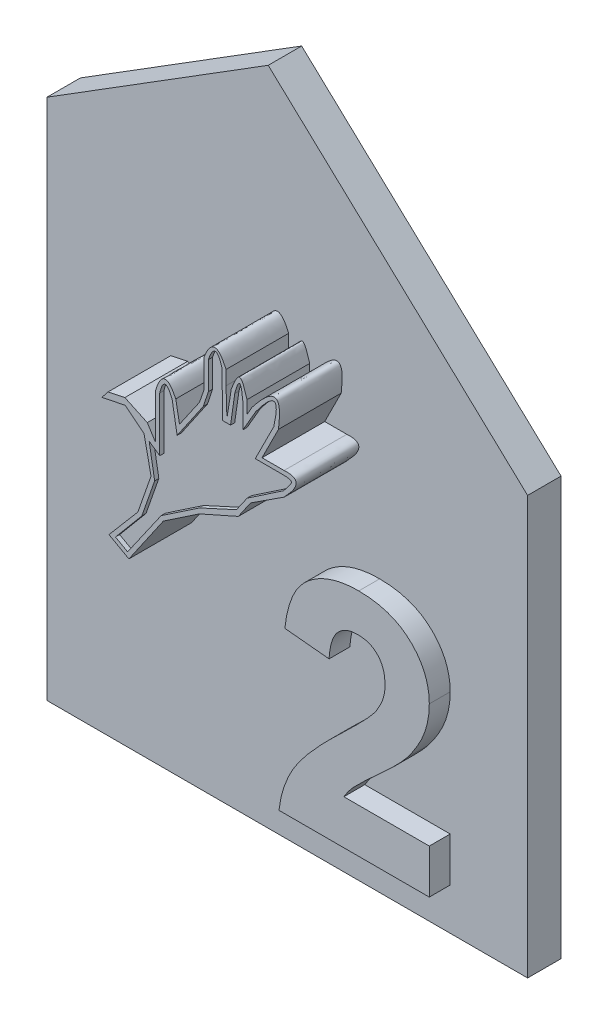
from build123d import *

# Parameters (mm, degrees)
P_IDAT_VYSUNUT_M5_DEPTH = 1.6
P_IDAT_VYSUNUT_M6_DEPTH = 1
P_IDAT_VYSUNUT_M7_DEPTH = 3
CUT_EXTRUDE6_DEPTH      = 3
CUT_EXTRUDE7_DEPTH      = 0.2


with BuildPart() as part:
    # Skica1 → Přidat vysunutím5 (new body)
    with BuildSketch(Plane.XY):
        Polygon((0, 0), (0, 20), (-12.412784718, 31.615626352), (-23, 25), (-23, 0), align=None)
    extrude(amount=P_IDAT_VYSUNUT_M5_DEPTH)

    # Skica2 → Přidat vysunutím6 (add)
    with BuildSketch(Plane.XY.offset(1.6)):
        with BuildLine():
            Line((-3.705128205, 4.115384615), (-3.705128205, 2))
            Line((-3.705128205, 2), (-10.897435897, 2))
            add(Edge.make_bspline(
                [(-10.897435897, 2), (-10.87308441, 2.180790308), (-10.824395089, 2.542269551), (-10.673865117, 3.070299742), (-10.472959166, 3.585566992), (-10.254913916, 4.004869463), (-10.038043764, 4.342393523), (-9.841277463, 4.618963346), (-9.60654249, 4.913221767), (-9.337245105, 5.227544267), (-9.034873554, 5.562913411), (-8.697171951, 5.918082368), (-8.322529407, 6.291350846), (-8.058961705, 6.54481851), (-7.922676282, 6.67588141)],
                knots=[0, 0, 0, 0, 0.000546661, 0.001093015, 0.001642153, 0.002203944, 0.002507135, 0.00284526, 0.003221747, 0.003635945, 0.00408685, 0.004576261, 0.005106025, 0.00567326, 0.00567326, 0.00567326, 0.00567326], degree=3))
            add(Edge.make_bspline(
                [(-7.922676282, 6.67588141), (-7.813918956, 6.780862005), (-7.606877039, 6.980714138), (-7.312048947, 7.266894293), (-7.052864674, 7.529975199), (-6.823905036, 7.763139303), (-6.630459323, 7.972323552), (-6.469982936, 8.154242742), (-6.34044346, 8.309637702), (-6.270284768, 8.408220362), (-6.239182692, 8.451923077)],
                knots=[0, 0, 0, 0, 0.000453482, 0.000863296, 0.001232576, 0.001561374, 0.001843606, 0.002087173, 0.00228919, 0.002450062, 0.002450062, 0.002450062, 0.002450062], degree=3))
            add(Edge.make_bspline(
                [(-6.239182692, 8.451923077), (-6.175493233, 8.557718073), (-6.052643645, 8.761784362), (-5.91792888, 9.082682292), (-5.837068057, 9.403513936), (-5.825971765, 9.617891805), (-5.820512821, 9.723357372)],
                knots=[0, 0, 0, 0, 0.000370068, 0.000713818, 0.001040364, 0.001356575, 0.001356575, 0.001356575, 0.001356575], degree=3))
            add(Edge.make_bspline(
                [(-5.820512821, 9.723357372), (-5.824474653, 9.833108474), (-5.831970132, 10.040748999), (-5.894821019, 10.333768175), (-6.006276867, 10.585659667), (-6.15973106, 10.797196661), (-6.353774193, 10.962935085), (-6.580616259, 11.085399693), (-6.843577862, 11.153106661), (-7.028402789, 11.16201224), (-7.125, 11.166666667)],
                knots=[0, 0, 0, 0, 0.000329064, 0.000622563, 0.000892834, 0.001149779, 0.00139978, 0.001652148, 0.001916728, 0.002206405, 0.002206405, 0.002206405, 0.002206405], degree=3))
            add(Edge.make_bspline(
                [(-7.125, 11.166666667), (-7.220944609, 11.16231978), (-7.406288878, 11.153922533), (-7.669703299, 11.080565334), (-7.900142302, 10.953576306), (-8.06436539, 10.808860058), (-8.175305876, 10.668134018), (-8.250896853, 10.545500545), (-8.316050374, 10.406151312), (-8.37378183, 10.251655158), (-8.419383153, 10.080242168), (-8.456107626, 9.893217825), (-8.485702239, 9.689575671), (-8.495113848, 9.547907653), (-8.5, 9.474358974)],
                knots=[0, 0, 0, 0, 0.000287482, 0.000555353, 0.000811759, 0.001070877, 0.001205779, 0.00134826, 0.001502018, 0.001666561, 0.00184243, 0.002033439, 0.002238177, 0.002459233, 0.002459233, 0.002459233, 0.002459233], degree=3))
            Line((-8.5, 9.474358974), (-10.615384615, 9.681490385))
            add(Edge.make_bspline(
                [(-10.615384615, 9.681490385), (-10.598377251, 9.824305509), (-10.565402688, 10.101201217), (-10.483114114, 10.498918926), (-10.378898684, 10.865831465), (-10.247788098, 11.201257911), (-10.095201314, 11.507331251), (-9.913355139, 11.779458664), (-9.708603468, 12.020654551), (-9.480769352, 12.230790543), (-9.231301205, 12.410535137), (-8.969529148, 12.57098477), (-8.690337423, 12.702604473), (-8.396799939, 12.811078884), (-8.089049352, 12.897770766), (-7.765662274, 12.955090263), (-7.42863453, 12.995409017), (-7.198577984, 12.998446608), (-7.080929487, 13)],
                knots=[0, 0, 0, 0, 0.000431306, 0.000836233, 0.001217004, 0.001574233, 0.001915203, 0.002240945, 0.002553567, 0.002862328, 0.003168197, 0.003474678, 0.003782194, 0.004092453, 0.004412693, 0.004739863, 0.005076887, 0.005429623, 0.005429623, 0.005429623, 0.005429623], degree=3))
            add(Edge.make_bspline(
                [(-7.080929487, 13), (-6.953030371, 12.997541845), (-6.703930784, 12.992754281), (-6.34028961, 12.953218534), (-5.998674853, 12.884282231), (-5.676099879, 12.79296634), (-5.375877361, 12.67105295), (-5.095505554, 12.52366473), (-4.83939702, 12.345207999), (-4.603734114, 12.145414763), (-4.393070332, 11.925706984), (-4.20854792, 11.691351493), (-4.053955652, 11.442511564), (-3.924228998, 11.182220281), (-3.827907833, 10.90628918), (-3.757724044, 10.618533633), (-3.711189366, 10.317611197), (-3.707170936, 10.112088), (-3.705128205, 10.007612179)],
                knots=[0, 0, 0, 0, 0.000383641, 0.00074719, 0.0010955, 0.001428145, 0.001751403, 0.002065859, 0.002376361, 0.002685876, 0.002991333, 0.003287991, 0.003579024, 0.003868752, 0.004158681, 0.00445369, 0.004756592, 0.005069772, 0.005069772, 0.005069772, 0.005069772], degree=3))
            add(Edge.make_bspline(
                [(-3.705128205, 10.007612179), (-3.707819477, 9.887707131), (-3.713158546, 9.649833916), (-3.764276175, 9.298186238), (-3.84237396, 8.954647512), (-3.957796338, 8.618378159), (-4.104103161, 8.28131186), (-4.292696164, 7.942692037), (-4.511666905, 7.592306518), (-4.683112364, 7.36576699), (-4.771634615, 7.248798077)],
                knots=[0, 0, 0, 0, 0.000359506, 0.000713204, 0.001063842, 0.00141504, 0.001778167, 0.002164709, 0.002576738, 0.003016589, 0.003016589, 0.003016589, 0.003016589], degree=3))
            add(Edge.make_bspline(
                [(-4.771634615, 7.248798077), (-4.80509214, 7.206658226), (-4.876750403, 7.116404431), (-4.998659939, 6.978014195), (-5.139942605, 6.826848432), (-5.298602846, 6.660077667), (-5.479881522, 6.483607708), (-5.677256214, 6.290058721), (-5.899411985, 6.089331377), (-6.12951153, 5.876418507), (-6.360611244, 5.669193404), (-6.5730252, 5.472375498), (-6.765967752, 5.298233923), (-6.930453202, 5.137155265), (-7.076156545, 5.000133027), (-7.197826149, 4.880140867), (-7.29773874, 4.780083699), (-7.43541186, 4.624119958), (-7.610585282, 4.413178934), (-7.733826947, 4.21161882), (-7.792668269, 4.115384615)],
                knots=[0, 0, 0, 0, 0.0001614, 0.000345681, 0.000553058, 0.000782151, 0.00103613, 0.001311959, 0.001611379, 0.001934216, 0.002252456, 0.002542536, 0.002802971, 0.003032064, 0.003233117, 0.00340296, 0.003544758, 0.003657116, 0.004027059, 0.004365069, 0.004365069, 0.004365069, 0.004365069], degree=3))
            Line((-7.792668269, 4.115384615), (-3.705128205, 4.115384615))
        make_face()
    extrude(amount=P_IDAT_VYSUNUT_M6_DEPTH)

    # Skica3 → Přidat vysunutím7 (add)
    with BuildSketch(Plane.XY.offset(1.6)):
        Polygon((-15.200672089, 8.988396037), (-6.42438967, 19.447562139), (-11.786700772, 23.947075407), (-20.562983191, 13.487909304), align=None)
    extrude(amount=P_IDAT_VYSUNUT_M7_DEPTH)

    # Sketch3 → Cut-Extrude6 (cut)
    with BuildSketch(Plane.XY.offset(4.6)):
        Polygon((-11.786700772, 23.947075407), (-20.562983191, 13.487909304), (-15.200672089, 8.988396037), (-6.42438967, 19.447562139), align=None)
        with BuildLine():
            Line((-16.457465684, 12.03395383), (-15.649238345, 12.984304532))
            Line((-15.649238345, 12.984304532), (-15.019514859, 14.787097071))
            Line((-15.019514859, 14.787097071), (-15.355910226, 16.391207117))
            Line((-15.355910226, 16.391207117), (-15.866003591, 16.794857693))
            Line((-15.866003591, 16.794857693), (-16.259420091, 17.106178734))
            Line((-16.259420091, 17.106178734), (-17.374686224, 16.872298047))
            Line((-17.374686224, 16.872298047), (-17.07620328, 17.249491041))
            Line((-17.07620328, 17.249491041), (-16.270685395, 17.418414916))
            Line((-16.270685395, 17.418414916), (-15.199536528, 16.916634307))
            Line((-15.199536528, 16.916634307), (-14.802570089, 16.290043062))
            Line((-14.802570089, 16.290043062), (-14.802570089, 17.618982408))
            Line((-14.802570089, 17.618982408), (-14.802570089, 18.446125661))
            add(Edge.make_bspline(
                [(-14.802570089, 18.446125661), (-14.409402354, 19.767045322), (-13.834511096, 18.58113986)],
                knots=[0, 0, 0, 1, 1, 1], degree=2))
            Line((-13.834511096, 18.58113986), (-13.657662622, 17.618982408))
            Line((-13.657662622, 17.618982408), (-13.285722013, 18.158442123))
            Line((-13.285722013, 18.158442123), (-12.702848264, 19.003837597))
            Line((-12.702848264, 19.003837597), (-12.479450228, 19.643388638))
            Line((-12.479450228, 19.643388638), (-12.479450228, 21.000423869))
            add(Edge.make_bspline(
                [(-11.430813737, 21.002569884), (-11.983407944, 22.285066315), (-12.479450228, 21.000423869)],
                knots=[0, 0, 0, 1, 1, 1], degree=2))
            Line((-11.430813737, 21.002569884), (-11.430813737, 20.325214012))
            Line((-11.430813737, 20.325214012), (-11.388721278, 19.003837597))
            Line((-11.388721278, 19.003837597), (-11.17829066, 20.325214012))
            add(Edge.make_bspline(
                [(-11.17829066, 20.325214012), (-11.042073241, 20.663221067), (-10.761959666, 21.358289029), (-10.539899146, 20.629713132), (-10.425825221, 20.255438982)],
                knots=[0, 0, 0, 0, 0.486293533, 1, 1, 1, 1], degree=3))
            Line((-10.425825221, 20.255438982), (-10.425825221, 19.643388638))
            Line((-10.425825221, 19.643388638), (-10.186341353, 20.055016643))
            add(Edge.make_bspline(
                [(-8.920322715, 19.776603485), (-8.61367595, 22.096828859), (-10.186341353, 20.055016643)],
                knots=[0, 0, 0, 1, 1, 1], degree=2))
            Line((-8.920322715, 19.776603485), (-9.708136566, 18.20540066))
            Line((-9.708136566, 18.20540066), (-8.65189408, 18.20540066))
            add(Edge.make_bspline(
                [(-8.65189408, 18.20540066), (-7.499916876, 18.276546548), (-8.65189408, 17.106178734)],
                knots=[0, 0, 0, 1, 1, 1], degree=2))
            Line((-8.65189408, 17.106178734), (-8.644667755, 17.106178734))
            Line((-8.644667755, 17.106178734), (-10.257165941, 16.057907946))
            Line((-10.257165941, 16.057907946), (-10.844162783, 15.206532371))
            Line((-10.844162783, 15.206532371), (-12.702848264, 14.381497444))
            Line((-12.702848264, 14.381497444), (-14.427564107, 13.223290812))
            Line((-14.427564107, 13.223290812), (-16.079379191, 10.827511285))
            Line((-16.079379191, 10.827511285), (-17.03160962, 11.358849109))
            Line((-17.03160962, 11.358849109), (-16.457465684, 12.03395383))
        make_face(mode=Mode.SUBTRACT)
    extrude(amount=-CUT_EXTRUDE6_DEPTH, mode=Mode.SUBTRACT)

    # Sketch5 → Cut-Extrude7 (cut)
    with BuildSketch(Plane.XY.offset(4.6)):
        with BuildLine():
            Line((-12.279450228, 20.982268299), (-12.279450228, 19.656193016))
            Line((-12.279450228, 19.656193016), (-12.517332694, 18.929111609))
            Line((-12.517332694, 18.929111609), (-13.770429434, 17.10065153))
            Line((-13.770429434, 17.10065153), (-14.012201969, 18.489346866))
            add(Edge.make_bspline(
                [(-14.012201969, 18.489346866), (-14.385135893, 19.395235164), (-14.602815852, 18.436213805)],
                knots=[0, 0, 0, 1, 1, 1], degree=2))
            Line((-14.602815852, 18.436213805), (-14.602815852, 15.842469943))
            Line((-14.602815852, 15.842469943), (-15.109272562, 16.18955942))
            Line((-15.109272562, 16.18955942), (-14.845997345, 14.677356779))
            Line((-14.845997345, 14.677356779), (-15.460425762, 12.918351453))
            Line((-15.460425762, 12.918351453), (-16.721463561, 11.414818722))
            Line((-16.721463561, 11.414818722), (-16.140778745, 11.090800714))
            Line((-16.140778745, 11.090800714), (-14.53649172, 13.391025052))
            Line((-14.53649172, 13.391025052), (-12.698454998, 14.631458839))
            Line((-12.698454998, 14.631458839), (-10.931095434, 15.440930993))
            Line((-10.931095434, 15.440930993), (-10.416217289, 16.179162508))
            Line((-10.416217289, 16.179162508), (-8.674862639, 17.354348573))
            add(Edge.make_bspline(
                [(-8.674862639, 17.354348573), (-8.25588993, 17.912910348), (-8.059947991, 18.00540066), (-8.824615445, 18.00540066)],
                knots=[0, 0, 0, 0, 1, 1, 1, 1], degree=3))
            Line((-8.824615445, 18.00540066), (-10.032151074, 18.00540066))
            Line((-10.032151074, 18.00540066), (-9.147477068, 19.769779768))
            add(Edge.make_bspline(
                [(-9.147477068, 19.769779768), (-8.683100918, 21.777671566), (-10.005537933, 19.969517383)],
                knots=[0, 0, 0, 1, 1, 1], degree=2))
            Line((-10.005537933, 19.969517383), (-10.625825221, 18.899741162))
            Line((-10.625825221, 18.899741162), (-10.625825221, 20.077819198))
            add(Edge.make_bspline(
                [(-10.625825221, 20.077819198), (-10.734536256, 21.341999481), (-11.01294279, 20.212696984)],
                knots=[0, 0, 0, 1, 1, 1], degree=2))
            Line((-11.01294279, 20.212696984), (-11.215408382, 18.803837597))
            Line((-11.215408382, 18.803837597), (-11.588386712, 18.803837597))
            Line((-11.588386712, 18.803837597), (-11.628764663, 20.974014133))
            add(Edge.make_bspline(
                [(-11.628764663, 20.974014133), (-11.925250415, 22.018897794), (-12.279450228, 20.982268299)],
                knots=[0, 0, 0, 1, 1, 1], degree=2))
        make_face()
    extrude(amount=-CUT_EXTRUDE7_DEPTH, mode=Mode.SUBTRACT)


solid = part.part
